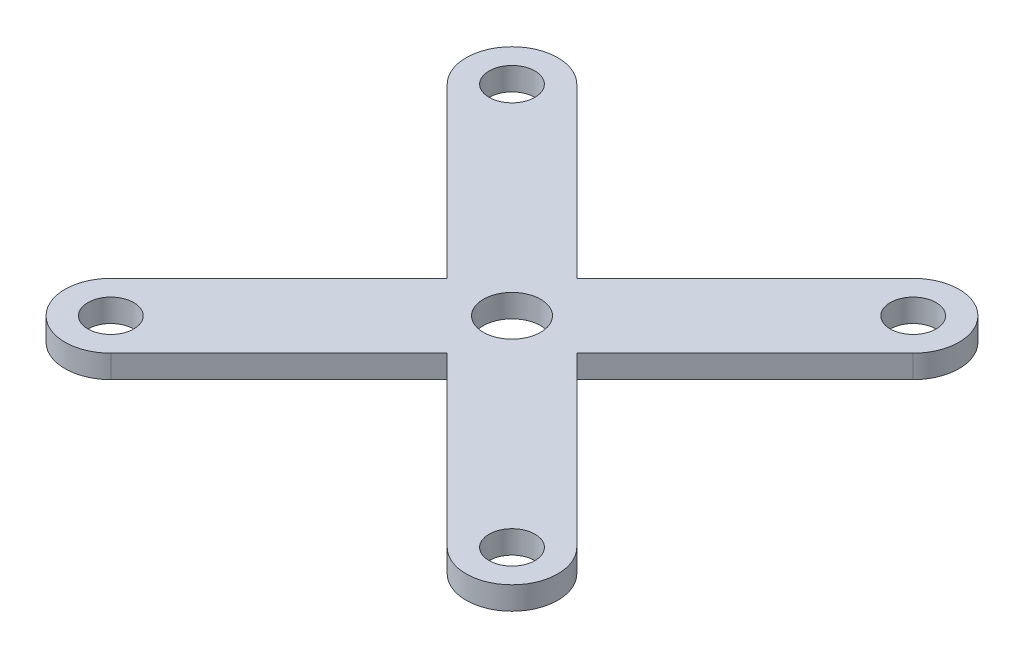
from build123d import *

# Parameters (mm, degrees)
SKETCH1_R           = 2
BOSS_EXTRUDE1_DEPTH = 2
SKETCH2_R           = 2.5
CUT_EXTRUDE1_DEPTH  = 2


with BuildPart() as part:
    # Sketch1 → Boss-Extrude1 (new body)
    with BuildSketch(Plane(origin=(0, 0, 0), x_dir=(1, 0, 0), z_dir=(0, 1, 0))):
        with BuildLine():
            Line((-5.656854249, 0), (-20.329319959, -14.67246571))
            ThreePointArc((-20.329319959, -14.67246571), (-20.329319959, -20.329319959), (-14.67246571, -20.329319959))
            Line((-14.67246571, -20.329319959), (0, -5.656854249))
            Line((0, -5.656854249), (14.67246571, -20.329319959))
            ThreePointArc((14.67246571, -20.329319959), (20.329319959, -20.329319959), (20.329319959, -14.67246571))
            Line((20.329319959, -14.67246571), (5.656854249, 0))
            Line((5.656854249, 0), (20.329319959, 14.67246571))
            ThreePointArc((20.329319959, 14.67246571), (20.329319959, 20.329319959), (14.67246571, 20.329319959))
            Line((14.67246571, 20.329319959), (0, 5.656854249))
            Line((0, 5.656854249), (-14.67246571, 20.329319959))
            ThreePointArc((-14.67246571, 20.329319959), (-20.329319959, 20.329319959), (-20.329319959, 14.67246571))
            Line((-20.329319959, 14.67246571), (-5.656854249, 0))
        make_face()
        with Locations((-17.500892834, 17.500892834)):
            Circle(SKETCH1_R, mode=Mode.SUBTRACT)
        with Locations((17.500892834, 17.500892834)):
            Circle(SKETCH1_R, mode=Mode.SUBTRACT)
        with Locations((17.500892834, -17.500892834)):
            Circle(SKETCH1_R, mode=Mode.SUBTRACT)
        with Locations((-17.500892834, -17.500892834)):
            Circle(SKETCH1_R, mode=Mode.SUBTRACT)
    extrude(amount=BOSS_EXTRUDE1_DEPTH)

    # Sketch2 → Cut-Extrude1 (cut)
    with BuildSketch(Plane(origin=(0, 2, 0), x_dir=(1, 0, 0), z_dir=(0, 1, 0))):
        Circle(SKETCH2_R)
    extrude(amount=-CUT_EXTRUDE1_DEPTH, mode=Mode.SUBTRACT)


solid = part.part
